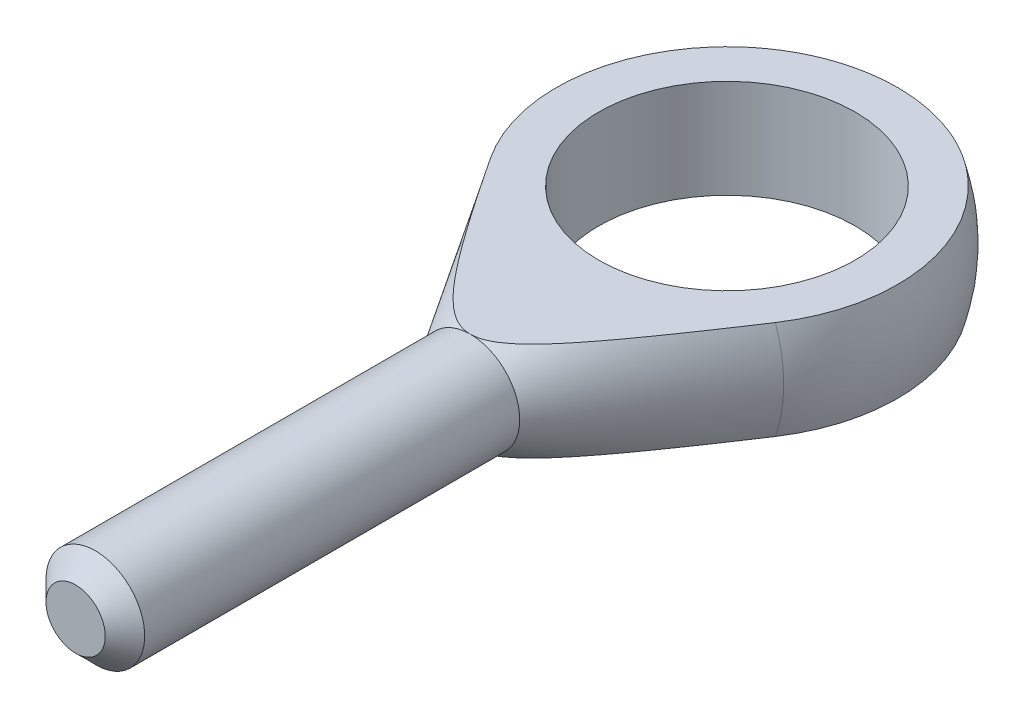
from build123d import *

# Parameters (mm, degrees)
SZKIC1_W                        = 2.5
SZKIC1_H                        = 20
WYTNIJ_WYCI_GNI_CIE1_DEPTH      = 10
WYTNIJ_WYCI_GNI_CIE1_DEPTH_BACK = 10
SZKIC3_R                        = 6.5
WYTNIJ_WYCI_GNI_CIE2_DEPTH      = 3.5
WYTNIJ_WYCI_GNI_CIE2_DEPTH_BACK = 3.5
SFAZOWANIE1_SIZE                = 1


with BuildPart() as part:
    # Szkic1 → Obrót1 (revolve)
    with BuildSketch(Plane(origin=(0, 0, 0), x_dir=(1, 0, 0), z_dir=(0, 1, 0))):
        with BuildLine():
            Line((0, 9), (0, -13))
            Line((0, -13), (2.5, -13))
            Line((2.5, -13), (7.636887524, -4.762137015))
            ThreePointArc((7.636887524, -4.762137015), (7.869537252, 4.366965014), (0, 9))
        make_face()
        with Locations((1.25, -23)):
            Rectangle(SZKIC1_W, SZKIC1_H)
    revolve(axis=Axis((0, 0, -26.043516498), (0, 0, 1)))

    # Szkic2 → Wytnij-wyciągnięcie1 (cut, two sides)
    with BuildSketch(Plane(origin=(0, 0, 0), x_dir=(0, 0, -1), z_dir=(1, 0, 0))) as wytnij_wyci_gni_cie1_sk:
        with BuildLine():
            Line((-13, 2.5), (8.645808233, 2.5))
            ThreePointArc((8.645808233, 2.5), (3.21988026, 8.4043067), (-4.762137015, 7.636887524))
            Line((-4.762137015, 7.636887524), (-13, 2.5))
        make_face()
        with BuildLine():
            Line((-13, -2.5), (8.645808233, -2.5))
            ThreePointArc((8.645808233, -2.5), (3.21988026, -8.4043067), (-4.762137015, -7.636887524))
            Line((-4.762137015, -7.636887524), (-13, -2.5))
        make_face()
    extrude(amount=WYTNIJ_WYCI_GNI_CIE1_DEPTH, mode=Mode.SUBTRACT)
    extrude(wytnij_wyci_gni_cie1_sk.sketch, amount=-WYTNIJ_WYCI_GNI_CIE1_DEPTH_BACK, mode=Mode.SUBTRACT)

    # Szkic3 → Wytnij-wyciągnięcie2 (cut, two sides)
    with BuildSketch(Plane(origin=(0, 0, 0), x_dir=(1, 0, 0), z_dir=(0, 1, 0))) as wytnij_wyci_gni_cie2_sk:
        Circle(SZKIC3_R)
    extrude(amount=WYTNIJ_WYCI_GNI_CIE2_DEPTH, mode=Mode.SUBTRACT)
    extrude(wytnij_wyci_gni_cie2_sk.sketch, amount=-WYTNIJ_WYCI_GNI_CIE2_DEPTH_BACK, mode=Mode.SUBTRACT)

    # Sfazowanie1
    sfazowanie1_edges = [part.edges().sort_by_distance(p)[0] for p in [
        (-2.5, 0, 33),
    ]]
    chamfer(sfazowanie1_edges, length=SFAZOWANIE1_SIZE)


solid = part.part
